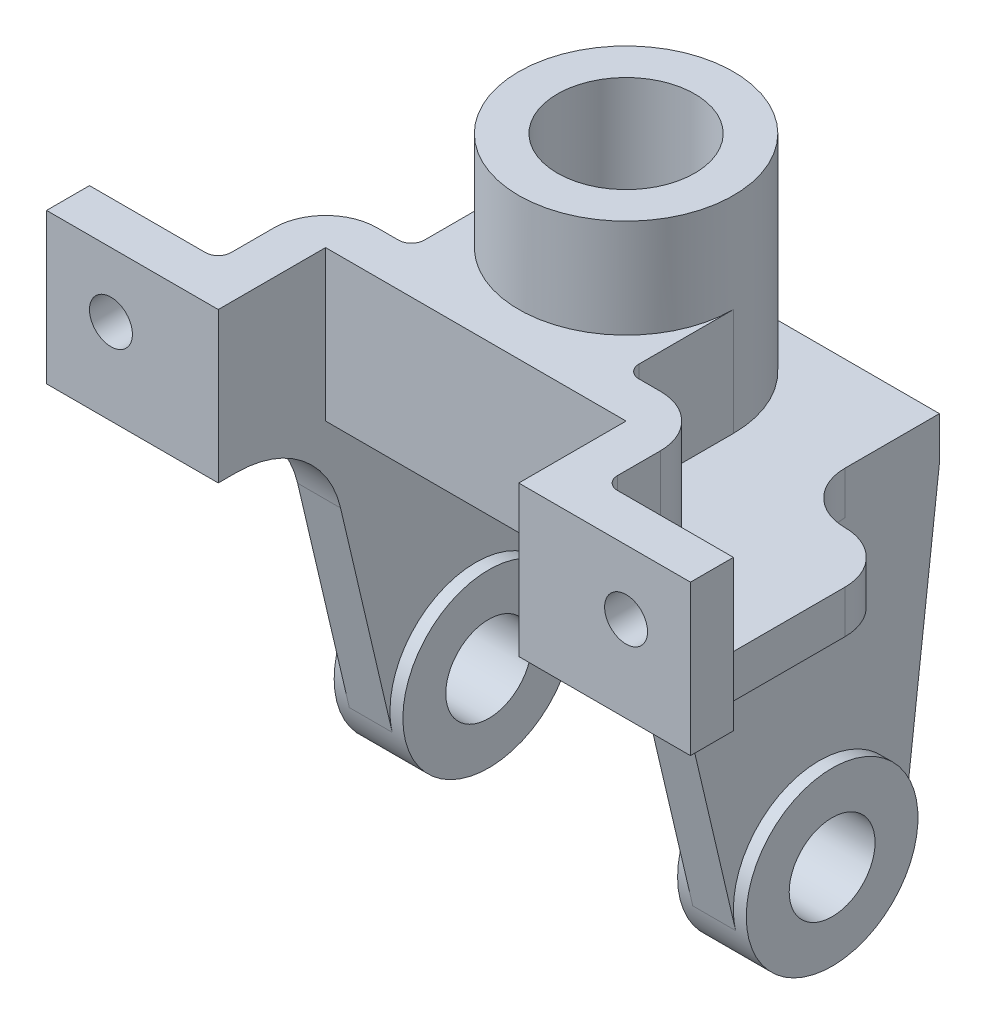
from build123d import *

# Parameters (mm, degrees)
BOSS_EXTRUDE1_DEPTH  = 10
SKETCH2_R            = 25
BOSS_EXTRUDE2_DEPTH  = 48
SKETCH3_R            = 16
CUT_EXTRUDE1_DEPTH   = 59
BOSS_EXTRUDE3_DEPTH  = 25
BOSS_EXTRUDE5_DEPTH  = 10
SKETCH6_R            = 20
BOSS_EXTRUDE6_DEPTH  = 8
SKETCH7_R            = 10
CUT_EXTRUDE2_DEPTH   = 16
FILLET1_R            = 25
FILLET1_OF_MIRROR1_R = 25
CUT_EXTRUDE3_REACH   = 12
SKETCH8_R            = 5


with BuildPart() as part:
    # Sketch1 → Boss-Extrude1 (new body)
    with BuildSketch(Plane(origin=(0, 0, 0), x_dir=(1, 0, 0), z_dir=(0, 1, 0))):
        with BuildLine():
            Line((-45, 28), (45, 28))
            Line((45, 28), (45, 6))
            ThreePointArc((45, 6), (48.514718626, -2.485281374), (57, -6))
            ThreePointArc((57, -6), (65.485281374, -9.514718626), (69, -18))
            Line((69, -18), (69, -50))
            Line((69, -50), (75, -50))
            Line((75, -50), (75, -60))
            Line((75, -60), (35, -60))
            Line((35, -60), (35, -35))
            Line((35, -35), (-35, -35))
            Line((-35, -35), (-35, -60))
            Line((-35, -60), (-75, -60))
            Line((-75, -60), (-75, -50))
            Line((-75, -50), (-69, -50))
            Line((-69, -50), (-69, -18))
            ThreePointArc((-69, -18), (-65.485281374, -9.514718626), (-57, -6))
            ThreePointArc((-57, -6), (-48.514718626, -2.485281374), (-45, 6))
            Line((-45, 6), (-45, 28))
        make_face()
    extrude(amount=BOSS_EXTRUDE1_DEPTH)

    # Sketch2 → Boss-Extrude2 (add)
    with BuildSketch(Plane(origin=(0, 10, 0), x_dir=(1, 0, 0), z_dir=(0, 1, 0))):
        with Locations(Location((0, 0, 0), (0, 0, 270))):  # turned: the seam where the file's is
            Circle(SKETCH2_R)
    extrude(amount=BOSS_EXTRUDE2_DEPTH)

    # Sketch3 → Cut-Extrude1 (cut, through all)
    with BuildSketch(Plane(origin=(0, 58, 0), x_dir=(1, 0, 0), z_dir=(0, 1, 0))):
        with Locations(Location((0, 0, 0), (0, 0, 270))):  # turned: the seam where the file's is
            Circle(SKETCH3_R)
    extrude(amount=-CUT_EXTRUDE1_DEPTH, mode=Mode.SUBTRACT)

    # Sketch4 → Boss-Extrude3 (add)
    with BuildSketch(Plane(origin=(0, 10, 0), x_dir=(1, 0, 0), z_dir=(0, 1, 0))):
        with BuildLine():
            Line((-25, 0), (-25, -22))
            ThreePointArc((-25, -22), (-25.878679656, -24.121320344), (-28, -25))
            Line((-28, -25), (-33, -25))
            ThreePointArc((-33, -25), (-41.485281374, -28.514718626), (-45, -37))
            Line((-45, -37), (-45, -47))
            ThreePointArc((-45, -47), (-45.878679656, -49.121320344), (-48, -50))
            Line((-48, -50), (-75, -50))
            Line((-75, -50), (-75, -60))
            Line((-75, -60), (-35, -60))
            Line((-35, -60), (-35, -35))
            Line((-35, -35), (35, -35))
            Line((35, -35), (35, -60))
            Line((35, -60), (75, -60))
            Line((75, -60), (75, -50))
            Line((75, -50), (48, -50))
            ThreePointArc((48, -50), (45.878679656, -49.121320344), (45, -47))
            Line((45, -47), (45, -37))
            ThreePointArc((45, -37), (41.485281374, -28.514718626), (33, -25))
            Line((33, -25), (28, -25))
            ThreePointArc((28, -25), (25.878679656, -24.121320344), (25, -22))
            Line((25, -22), (25, 0))
            ThreePointArc((25, 0), (0, -25), (-25, 0))
        make_face()
    extrude(amount=BOSS_EXTRUDE3_DEPTH)

    # Sketch5 → Boss-Extrude5 (add)
    with BuildSketch(Plane.ZY.offset(45)):
        with BuildLine():
            Line((-28, 0), (-19.859709814, -68.364725376))
            ThreePointArc((-19.859709814, -68.364725376), (-1.119802535, -85.96862645), (19.470806475, -70.570305811))
            Line((19.470806475, -70.570305811), (36.035496755, 0))
            Line((36.035496755, 0), (-28, 0))
        make_face()
    boss_extrude5 = extrude(amount=-BOSS_EXTRUDE5_DEPTH)

    # Sketch6 → Boss-Extrude6 (add, symmetric)
    with BuildSketch(Plane.ZY.offset(40)):
        with Locations((0, -66)):
            Circle(SKETCH6_R)
    boss_extrude6 = extrude(amount=BOSS_EXTRUDE6_DEPTH, both=True)

    # Sketch7 → Cut-Extrude2 (cut)
    with BuildSketch(Plane.ZY.offset(48)):
        with Locations((0, -66)):
            Circle(SKETCH7_R)
    cut_extrude2 = extrude(amount=-CUT_EXTRUDE2_DEPTH, mode=Mode.SUBTRACT)

    # Fillet1
    fillet1_edges = [part.edges().sort_by_distance(p)[0] for p in [
        (-40, 0, 36.035496755),
    ]]
    fillet(fillet1_edges, radius=FILLET1_R)

    # Mirror1: Boss-Extrude5, Boss-Extrude6, Cut-Extrude2 across plane
    add(boss_extrude5.mirror(Plane(origin=(0, 0, 0), x_dir=(0, 0, 1), z_dir=(1, 0, 0))))
    add(boss_extrude6.mirror(Plane(origin=(0, 0, 0), x_dir=(0, 0, 1), z_dir=(1, 0, 0))))
    add(cut_extrude2.mirror(Plane(origin=(0, 0, 0), x_dir=(0, 0, 1), z_dir=(1, 0, 0))), mode=Mode.SUBTRACT)

    # Fillet1 of Mirror1
    fillet1_of_mirror1_edges = [part.edges().sort_by_distance(p)[0] for p in [
        (40, 0, 36.035496755),
    ]]
    fillet(fillet1_of_mirror1_edges, radius=FILLET1_OF_MIRROR1_R)

    # Sketch8 → Cut-Extrude3 (cut, up to next)
    with BuildSketch(Plane(origin=(0, 0, 50), x_dir=(-1, 0, 0), z_dir=(0, 0, -1)), mode=Mode.PRIVATE) as cut_extrude3_sk1:
        with Locations((-60, 20)):
            Circle(SKETCH8_R)
    cut_extrude3_tool1 = extrude(cut_extrude3_sk1.sketch, amount=-CUT_EXTRUDE3_REACH, mode=Mode.PRIVATE) & part.part
    add(cut_extrude3_tool1.solids().sort_by_distance((60, 20, 50))[0], mode=Mode.SUBTRACT)
    # Sketch8 → Cut-Extrude3 (cut, up to next)
    with BuildSketch(Plane(origin=(0, 0, 50), x_dir=(-1, 0, 0), z_dir=(0, 0, -1)), mode=Mode.PRIVATE) as cut_extrude3_sk2:
        with Locations((60, 20)):
            Circle(SKETCH8_R)
    cut_extrude3_tool2 = extrude(cut_extrude3_sk2.sketch, amount=-CUT_EXTRUDE3_REACH, mode=Mode.PRIVATE) & part.part
    add(cut_extrude3_tool2.solids().sort_by_distance((-60, 20, 50))[0], mode=Mode.SUBTRACT)


solid = part.part
